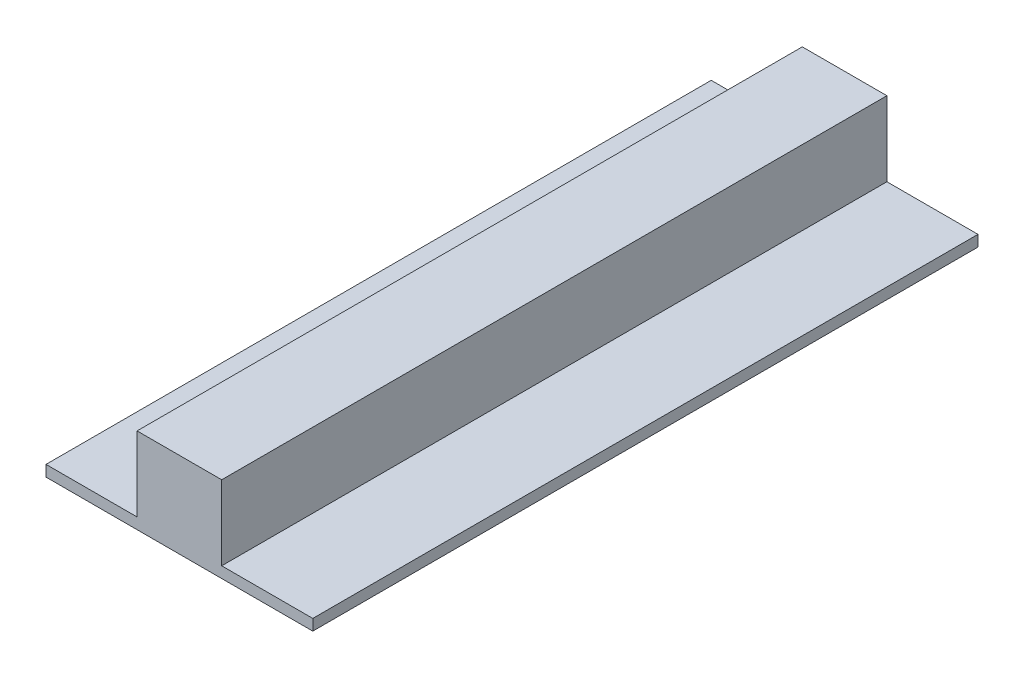
from build123d import *

# Parameters (mm, degrees)
BOSS_EXTRUDE1_DEPTH = 241


with BuildPart() as part:
    # Sketch1 → Boss-Extrude1 (new body)
    with BuildSketch(Plane.XY):
        Polygon((40.828426409, -15.5), (48.328426409, -15.5), (48.328426409, -11.5), (40.828426409, -11.5), (15.328426409, -11.5), (15.328426409, 15.5), (-15.328426409, 15.5), (-15.328426409, -11.5), (-40.828426409, -11.5), (-48.328426409, -11.5), (-48.328426409, -15.5), (-40.828426409, -15.5), align=None)
    extrude(amount=BOSS_EXTRUDE1_DEPTH)


solid = part.part
